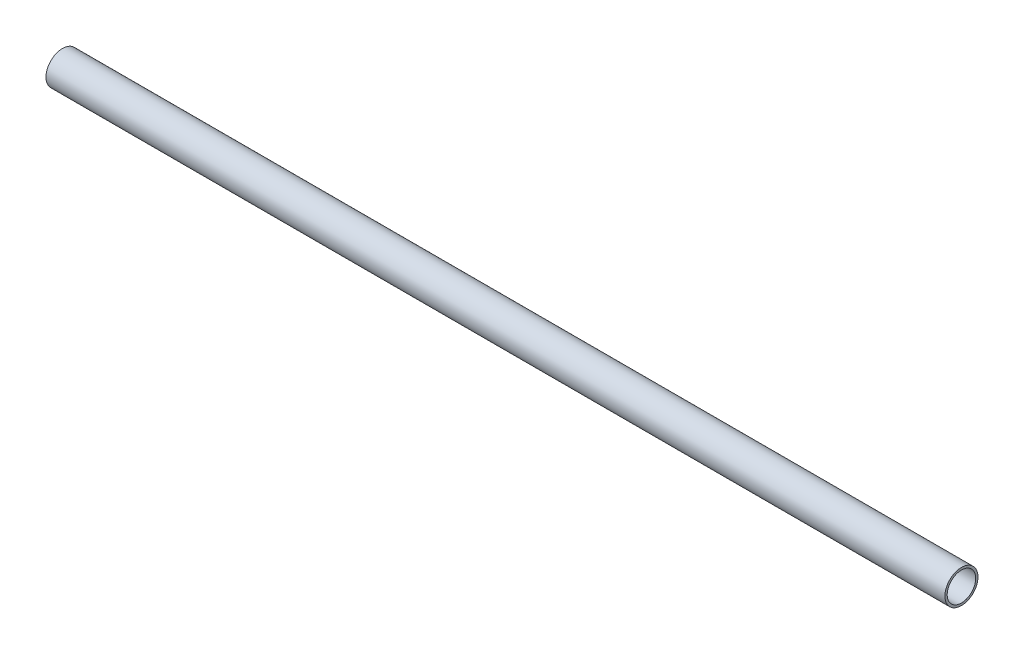
from build123d import *

# Parameters (mm, degrees)
SKETCH1_R           = 0.7366
SKETCH1_R_2         = 0.635
BOSS_EXTRUDE1_DEPTH = 40


with BuildPart() as part:
    # Sketch1 → Boss-Extrude1 (new body)
    with BuildSketch(Plane(origin=(0, 0, 0), x_dir=(0, 0, -1), z_dir=(1, 0, 0))):
        Circle(SKETCH1_R)
        Circle(SKETCH1_R_2, mode=Mode.SUBTRACT)
    extrude(amount=BOSS_EXTRUDE1_DEPTH)


solid = part.part
